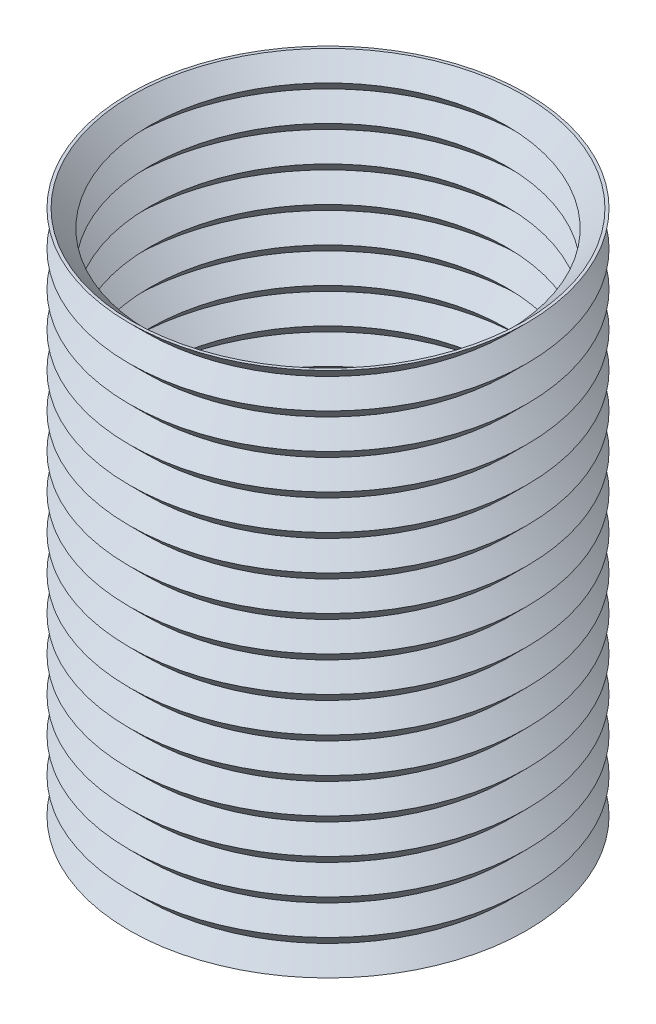
from build123d import *

# Parameters (mm, degrees)
SKORUPA1_T = -0.7


with BuildPart() as part:
    # Szkic1 → Obrót1 (revolve)
    with BuildSketch(Plane.XY, mode=Mode.PRIVATE) as obr_t1_sk:
        Polygon((0, 0), (68, 0), (62, 6), (68, 12), (62, 18), (68, 24), (62, 30), (68, 36), (62, 42), (68, 48), (62, 54), (68, 60), (62, 66), (68, 72), (62, 78), (68, 84), (62, 90), (68, 96), (62, 102), (68, 108), (62, 114), (68, 120), (62, 126), (68, 132), (62, 138), (68, 144), (62, 150), (68, 156), (62, 162), (68, 168), (62, 174), (68, 180), (0, 180), align=None)
    revolve(obr_t1_sk.sketch.rotate(Axis((0, 39.738115942, 0), (0, -1, 0)), 90), axis=Axis((0, 39.738115942, 0), (0, -1, 0)))

    # Skorupa1
    skorupa1_openings = [part.faces().sort_by_distance(p)[0] for p in [
        (0, 0, 0),
        (0, 180, 0),
    ]]
    offset(amount=SKORUPA1_T, openings=skorupa1_openings, kind=Kind.INTERSECTION)


solid = part.part
